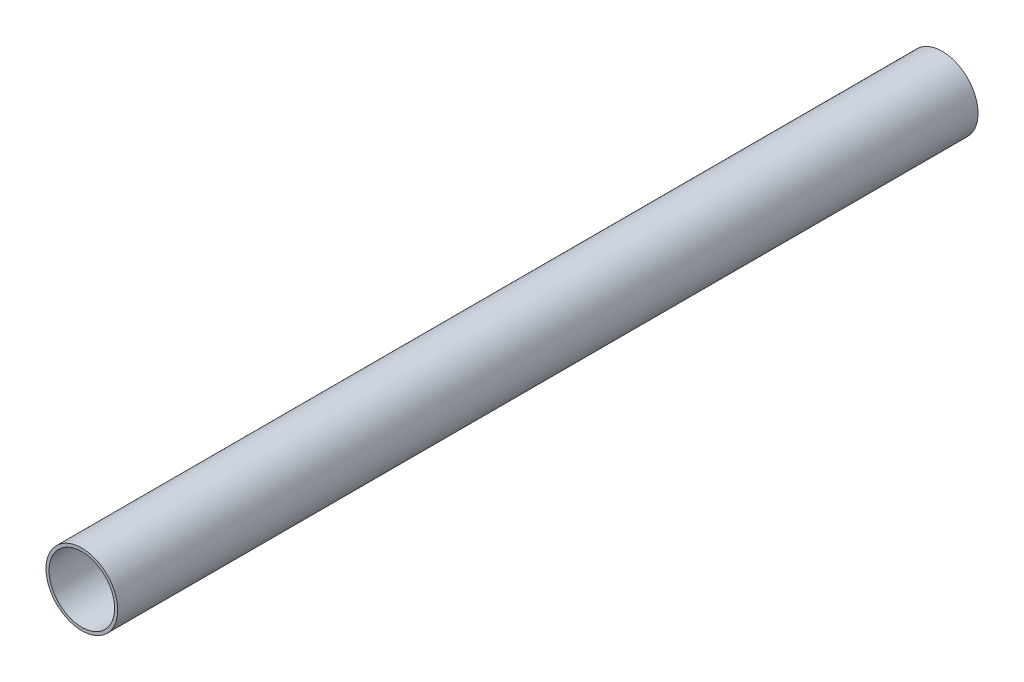
from build123d import *

# Parameters (mm, degrees)
SKETCH_1_W = 0.889
SKETCH_1_H = 250


with BuildPart() as part:
    # 草图1 → 旋转1 (revolve)
    with BuildSketch(Plane.XZ.offset(-70.710678119)):
        with Locations((-60.741178119, 86.9)):
            Rectangle(SKETCH_1_W, SKETCH_1_H)
    revolve(axis=Axis((-70.710678119, 70.710678119, 387.35), (0, 0, -1)))


solid = part.part
